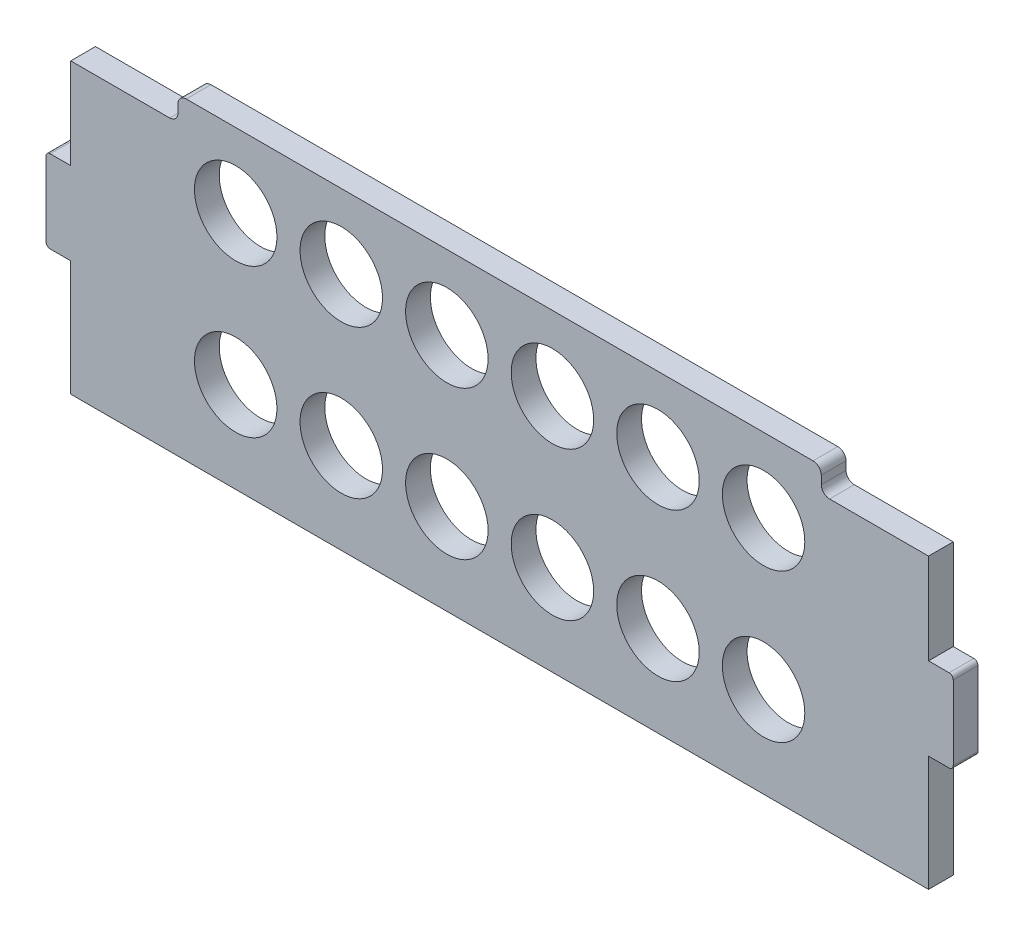
from build123d import *

# Parameters (mm, degrees)
SKETCH_1_R      = 5
EXTRUDE_1_DEPTH = 3
FILLET_1_R      = 0.5
FILLET_2_R      = 1
FILLET_3_R      = 1


with BuildPart() as part:
    # Эскиз1 → Бобышка-Вытянуть1 (new body)
    with BuildSketch(Plane.XY):
        Polygon((39, 19), (-39, 19), (-39, 16), (-52, 16), (-52, 5), (-55, 5), (-55, -5), (-52, -5), (-52, -19), (52, -19), (52, -5), (55, -5), (55, 5), (52, 5), (52, 16), (39, 16), align=None)
        with Locations((-32, -8)):
            Circle(SKETCH_1_R, mode=Mode.SUBTRACT)
        with Locations((-19.2, -8)):
            Circle(SKETCH_1_R, mode=Mode.SUBTRACT)
        with Locations((-6.4, -8)):
            Circle(SKETCH_1_R, mode=Mode.SUBTRACT)
        with Locations((6.4, -8)):
            Circle(SKETCH_1_R, mode=Mode.SUBTRACT)
        with Locations((19.2, -8)):
            Circle(SKETCH_1_R, mode=Mode.SUBTRACT)
        with Locations((32, -8)):
            Circle(SKETCH_1_R, mode=Mode.SUBTRACT)
        with Locations((-32, 10)):
            Circle(SKETCH_1_R, mode=Mode.SUBTRACT)
        with Locations((-19.2, 10)):
            Circle(SKETCH_1_R, mode=Mode.SUBTRACT)
        with Locations((-6.4, 10)):
            Circle(SKETCH_1_R, mode=Mode.SUBTRACT)
        with Locations((6.4, 10)):
            Circle(SKETCH_1_R, mode=Mode.SUBTRACT)
        with Locations((19.2, 10)):
            Circle(SKETCH_1_R, mode=Mode.SUBTRACT)
        with Locations((32, 10)):
            Circle(SKETCH_1_R, mode=Mode.SUBTRACT)
    extrude(amount=EXTRUDE_1_DEPTH)

    # Скругление1
    fillet_1_edges = [part.edges().sort_by_distance(p)[0] for p in [
        (55, 5, 1.5),
        (55, -5, 1.5),
        (-55, -5, 1.5),
        (-55, 5, 1.5),
    ]]
    fillet(fillet_1_edges, radius=FILLET_1_R)

    # Скругление2
    fillet_2_edges = [part.edges().sort_by_distance(p)[0] for p in [
        (-39, 16, 1.5),
        (-39, 19, 1.5),
    ]]
    fillet(fillet_2_edges, radius=FILLET_2_R)

    # Скругление3
    fillet_3_edges = [part.edges().sort_by_distance(p)[0] for p in [
        (39, 19, 1.5),
        (39, 16, 1.5),
    ]]
    fillet(fillet_3_edges, radius=FILLET_3_R)


solid = part.part
